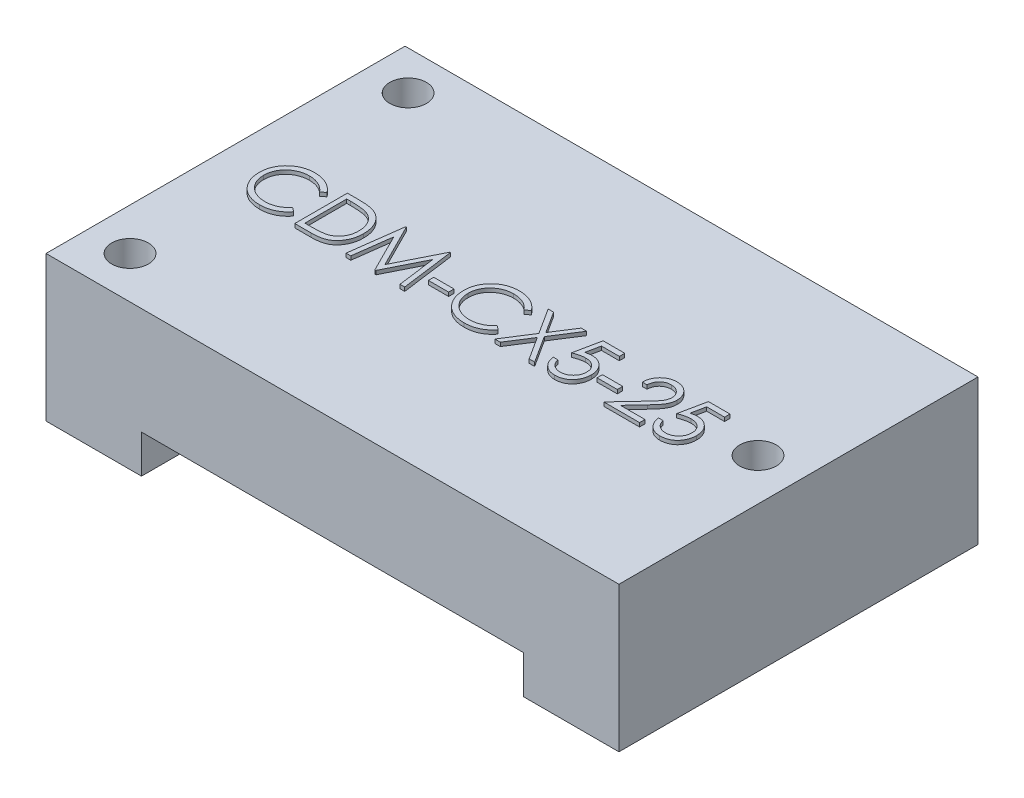
from build123d import *

# Parameters (mm, degrees)
SKETCH1_W               = 38.1
SKETCH1_H               = 23.876
SKETCH1_R               = 1.2192
BOSS_EXTRUDE1_DEPTH     = 9.652
SKETCH2_W               = 1.346153846
SKETCH2_H               = 0.358974359
BOSS_EXTRUDE2_DEPTH     = 0.254
SKETCH4_W               = 25.4
SKETCH4_H               = 2.54
CUT_EXTRUDE1_DEPTH      = 12.9380001
CUT_EXTRUDE1_DEPTH_BACK = 12.9380001


with BuildPart() as part:
    # Sketch1 → Boss-Extrude1 (new body)
    with BuildSketch(Plane(origin=(0, 0, 0), x_dir=(1, 0, 0), z_dir=(0, 1, 0))):
        Rectangle(SKETCH1_W, SKETCH1_H)
        with Locations((-16.256, 9.3472)):
            Circle(SKETCH1_R, mode=Mode.SUBTRACT)
        with Locations((-16.256, -9.144)):
            Circle(SKETCH1_R, mode=Mode.SUBTRACT)
        with Locations((16.256, 0.1016)):
            Circle(SKETCH1_R, mode=Mode.SUBTRACT)
    extrude(amount=-BOSS_EXTRUDE1_DEPTH)

    # Sketch2 → Boss-Extrude2 (add)
    with BuildSketch(Plane(origin=(0, 0, 0), x_dir=(1, 0, 0), z_dir=(0, 1, 0))):
        with BuildLine():
            Line((-12.967255042, 0.660782807), (-13.242094786, 0.450446269))
            add(Edge.make_bspline(
                [(-13.242094786, 0.450446269), (-13.261700674, 0.473812239), (-13.300648121, 0.520229154), (-13.363307324, 0.585408699), (-13.428608966, 0.64647396), (-13.496528088, 0.70371584), (-13.568287207, 0.755132606), (-13.642148006, 0.803403708), (-13.719346051, 0.846671446), (-13.826097786, 0.899134433), (-13.965745634, 0.953880588), (-14.141540473, 0.999783819), (-14.325051572, 1.029004995), (-14.450249171, 1.032169836), (-14.513929722, 1.033779602)],
                knots=[0, 0, 0, 0, 9.1485e-05, 0.000181737, 0.000271024, 0.000359627, 0.000447979, 0.000535687, 0.000624217, 0.000713268, 0.000892422, 0.00107303, 0.001257466, 0.001448389, 0.001448389, 0.001448389, 0.001448389], degree=3))
            add(Edge.make_bspline(
                [(-14.513929722, 1.033779602), (-14.549013021, 1.03337564), (-14.618854014, 1.032571464), (-14.722502487, 1.021962338), (-14.824215538, 1.007051128), (-14.923927005, 0.984925805), (-15.021509963, 0.956953186), (-15.117602365, 0.923527772), (-15.210812965, 0.882172932), (-15.302431203, 0.836464672), (-15.390210414, 0.784837228), (-15.473265462, 0.728523876), (-15.55129343, 0.668154779), (-15.624356042, 0.603503673), (-15.69252799, 0.534861712), (-15.755315301, 0.461497371), (-15.812500711, 0.383645197), (-15.865217736, 0.30233179), (-15.91243047, 0.217793998), (-15.951960349, 0.129718928), (-15.986965471, 0.039614825), (-16.014664714, -0.053536336), (-16.036589231, -0.149079102), (-16.051716894, -0.24726989), (-16.062205365, -0.347903569), (-16.063005542, -0.416112882), (-16.063408888, -0.450495238)],
                knots=[0, 0, 0, 0, 0.000105206, 0.000209435, 0.000312261, 0.00041348, 0.000515565, 0.000616682, 0.000718413, 0.000821258, 0.000923708, 0.001023662, 0.001122111, 0.001219464, 0.00131614, 0.001412112, 0.001508869, 0.001605718, 0.001702691, 0.001799013, 0.001895107, 0.001992482, 0.002090281, 0.00218895, 0.002290387, 0.00239349, 0.00239349, 0.00239349, 0.00239349], degree=3))
            add(Edge.make_bspline(
                [(-16.063408888, -0.450495238), (-16.062147069, -0.502226558), (-16.059669655, -0.603794142), (-16.037621321, -0.752564753), (-16.00411623, -0.895085427), (-15.953900653, -1.030465269), (-15.891981602, -1.160373627), (-15.813740991, -1.282612481), (-15.723124453, -1.399029045), (-15.618850034, -1.506871993), (-15.504444218, -1.605385718), (-15.381696306, -1.6921363), (-15.250912019, -1.764451182), (-15.113535388, -1.824627129), (-14.968509274, -1.870883856), (-14.816094472, -1.90344798), (-14.656622477, -1.92469016), (-14.547653077, -1.926723848), (-14.492194946, -1.927758859)],
                knots=[0, 0, 0, 0, 0.000155106, 0.000304531, 0.000450265, 0.000593548, 0.000736853, 0.000881182, 0.001028026, 0.001178769, 0.001330408, 0.001480379, 0.001628835, 0.001777978, 0.001929641, 0.002084627, 0.002245075, 0.00241136, 0.00241136, 0.00241136, 0.00241136], degree=3))
            add(Edge.make_bspline(
                [(-14.492194946, -1.927758859), (-14.431092257, -1.92607008), (-14.310827548, -1.922746157), (-14.134459522, -1.894586908), (-13.965623756, -1.84892899), (-13.80431117, -1.785031068), (-13.650976523, -1.70196578), (-13.505379863, -1.601267903), (-13.367398293, -1.48197957), (-13.28442701, -1.390896442), (-13.242094786, -1.344425526)],
                knots=[0, 0, 0, 0, 0.00018322, 0.00036062, 0.000534275, 0.000707044, 0.000879893, 0.001056289, 0.001237208, 0.001425665, 0.001425665, 0.001425665, 0.001425665], degree=3))
            Line((-13.242094786, -1.344425526), (-12.967255042, -1.552658699))
            add(Edge.make_bspline(
                [(-12.967255042, -1.552658699), (-12.989373152, -1.581197151), (-13.033503427, -1.638137357), (-13.104961444, -1.718409067), (-13.180238742, -1.793913103), (-13.259894452, -1.864040724), (-13.343012243, -1.930195189), (-13.431084556, -1.990497021), (-13.522953588, -2.045787905), (-13.618308067, -2.09641483), (-13.71704668, -2.141332077), (-13.819051115, -2.179785844), (-13.92388169, -2.212910734), (-14.031543199, -2.240162671), (-14.142258956, -2.261433754), (-14.25562943, -2.275653429), (-14.371899305, -2.285395344), (-14.450340726, -2.28628326), (-14.490091581, -2.286733218)],
                knots=[0, 0, 0, 0, 0.000108293, 0.000216068, 0.000322162, 0.000427957, 0.000534281, 0.00064066, 0.000747915, 0.000855806, 0.000964371, 0.001073102, 0.001182643, 0.001294024, 0.001406092, 0.001520624, 0.001636667, 0.001755891, 0.001755891, 0.001755891, 0.001755891], degree=3))
            add(Edge.make_bspline(
                [(-14.490091581, -2.286733218), (-14.527735248, -2.286471226), (-14.602170938, -2.285953168), (-14.712069689, -2.277561001), (-14.81905927, -2.266111264), (-14.922833896, -2.248871133), (-15.023959871, -2.228526793), (-15.121520456, -2.201255536), (-15.216475666, -2.170706369), (-15.308444007, -2.134801383), (-15.397503707, -2.0942852), (-15.483367518, -2.048493641), (-15.56599595, -1.997811777), (-15.646201371, -1.943356766), (-15.722798955, -1.883379464), (-15.79645248, -1.81871283), (-15.867574956, -1.749574819), (-15.911577641, -1.699719966), (-15.933701356, -1.674653892)],
                knots=[0, 0, 0, 0, 0.0001129, 0.000223246, 0.000330481, 0.000435603, 0.000538732, 0.000639764, 0.000739316, 0.000837878, 0.000935767, 0.001032686, 0.001129604, 0.00122645, 0.001323362, 0.001421241, 0.001520399, 0.001620667, 0.001620667, 0.001620667, 0.001620667], degree=3))
            add(Edge.make_bspline(
                [(-15.933701356, -1.674653892), (-15.969137, -1.631112703), (-16.039580477, -1.544555992), (-16.12970616, -1.404270011), (-16.206853715, -1.257801802), (-16.269229636, -1.104381873), (-16.317992369, -0.944354486), (-16.351773564, -0.777638972), (-16.373725169, -0.604391029), (-16.376235458, -0.486554241), (-16.377511453, -0.426657097)],
                knots=[0, 0, 0, 0, 0.000168306, 0.00033458, 0.000499224, 0.000664315, 0.00083066, 0.00100034, 0.001174094, 0.001353718, 0.001353718, 0.001353718, 0.001353718], degree=3))
            add(Edge.make_bspline(
                [(-16.377511453, -0.426657097), (-16.375956259, -0.363701643), (-16.372896513, -0.239840719), (-16.346900717, -0.058066765), (-16.305081921, 0.116084634), (-16.245685032, 0.282288378), (-16.170379681, 0.441418658), (-16.077353067, 0.592259863), (-15.967685925, 0.735776663), (-15.842238357, 0.869791414), (-15.704671022, 0.992330767), (-15.557352208, 1.100136971), (-15.400570261, 1.189854487), (-15.23605241, 1.264850649), (-15.062566728, 1.322495112), (-14.880483359, 1.362848299), (-14.690144444, 1.387965415), (-14.560282018, 1.391140623), (-14.494298311, 1.392753961)],
                knots=[0, 0, 0, 0, 0.000188789, 0.000371431, 0.000549644, 0.000725278, 0.00089996, 0.001076844, 0.001255917, 0.001440951, 0.001626689, 0.001807878, 0.001987546, 0.002167657, 0.002349462, 0.002534866, 0.002726448, 0.002924344, 0.002924344, 0.002924344, 0.002924344], degree=3))
            add(Edge.make_bspline(
                [(-14.494298311, 1.392753961), (-14.45408384, 1.392271823), (-14.374483342, 1.391317479), (-14.25673069, 1.382011337), (-14.142088363, 1.366497731), (-14.030477381, 1.345381661), (-13.921354765, 1.319174339), (-13.815554524, 1.285034041), (-13.712455837, 1.24599751), (-13.612708929, 1.201039044), (-13.516792379, 1.150572302), (-13.42473606, 1.095156679), (-13.337271201, 1.034860873), (-13.253782353, 0.970197698), (-13.175666142, 0.899799139), (-13.100704663, 0.825601543), (-13.031443585, 0.745467718), (-12.98869039, 0.689062784), (-12.967255042, 0.660782807)],
                knots=[0, 0, 0, 0, 0.000120626, 0.000238766, 0.000354085, 0.000467531, 0.000579423, 0.000690512, 0.000800803, 0.000910007, 0.001018518, 0.001125773, 0.001232152, 0.001337058, 0.001442329, 0.001547432, 0.001653292, 0.001759736, 0.001759736, 0.001759736, 0.001759736], degree=3))
        make_face()
        with BuildLine():
            Line((-12.249306324, -2.196989629), (-12.249306324, 1.303010371))
            Line((-12.249306324, 1.303010371), (-11.542575555, 1.303010371))
            add(Edge.make_bspline(
                [(-11.542575555, 1.303010371), (-11.481106567, 1.302567801), (-11.362348802, 1.301712758), (-11.190736354, 1.296291367), (-11.031952592, 1.286700901), (-10.886519733, 1.272731375), (-10.754038521, 1.255578342), (-10.634879912, 1.234077937), (-10.52842777, 1.208689767), (-10.462958329, 1.187044317), (-10.431998632, 1.176808448)],
                knots=[0, 0, 0, 0, 0.000184407, 0.000356273, 0.000515031, 0.000661537, 0.000794508, 0.000915664, 0.001024665, 0.001122454, 0.001122454, 0.001122454, 0.001122454], degree=3))
            add(Edge.make_bspline(
                [(-10.431998632, 1.176808448), (-10.391503893, 1.161377743), (-10.3114327, 1.130866249), (-10.197425578, 1.073309947), (-10.090100215, 1.008096845), (-9.98888107, 0.935140983), (-9.896080244, 0.852376634), (-9.808072347, 0.763319549), (-9.728457623, 0.664731208), (-9.655549327, 0.55865622), (-9.589813668, 0.446344168), (-9.53267451, 0.32800906), (-9.485220516, 0.204251851), (-9.44582729, 0.075416703), (-9.414780832, -0.058779674), (-9.393598901, -0.19849354), (-9.379627911, -0.34317273), (-9.378223859, -0.441347194), (-9.377511453, -0.491160302)],
                knots=[0, 0, 0, 0, 0.000129935, 0.000256923, 0.000382457, 0.000506429, 0.000630624, 0.000755071, 0.000881654, 0.001010204, 0.001140916, 0.00127168, 0.001403968, 0.001538146, 0.001675568, 0.001816774, 0.001961818, 0.002111216, 0.002111216, 0.002111216, 0.002111216], degree=3))
            add(Edge.make_bspline(
                [(-9.377511453, -0.491160302), (-9.37814042, -0.53442154), (-9.379379866, -0.619672329), (-9.390509182, -0.745313225), (-9.406685502, -0.867226796), (-9.4317297, -0.984832496), (-9.462132213, -1.099160714), (-9.501096365, -1.208992958), (-9.545731861, -1.315336768), (-9.597781739, -1.416754244), (-9.654923124, -1.512837616), (-9.716244868, -1.603413144), (-9.781681563, -1.687188366), (-9.851857196, -1.764416978), (-9.925864912, -1.834982556), (-10.004189243, -1.899474572), (-10.087032294, -1.956631127), (-10.174023016, -2.008698235), (-10.267699146, -2.05411859), (-10.369835012, -2.0925486), (-10.48086619, -2.124395215), (-10.600520147, -2.150966111), (-10.729003624, -2.172043414), (-10.86644259, -2.186169806), (-11.01262588, -2.195722739), (-11.113005145, -2.196559132), (-11.164670908, -2.196989629)],
                knots=[0, 0, 0, 0, 0.000129755, 0.000255696, 0.000378151, 0.000498469, 0.000616165, 0.000732801, 0.000847787, 0.000961923, 0.00107447, 0.001182981, 0.001289856, 0.001393094, 0.001495748, 0.001596383, 0.00169713, 0.001797413, 0.001900265, 0.002008995, 0.002124372, 0.002246504, 0.002376522, 0.002514729, 0.002660846, 0.00281582, 0.00281582, 0.00281582, 0.00281582], degree=3))
            Line((-11.164670908, -2.196989629), (-12.249306324, -2.196989629))
        make_face()
        with BuildLine():
            Line((-11.93520376, -1.83801527), (-11.533460972, -1.83801527))
            add(Edge.make_bspline(
                [(-11.533460972, -1.83801527), (-11.475732601, -1.837767173), (-11.364699803, -1.837289993), (-11.205041805, -1.83310279), (-11.059162409, -1.826260853), (-10.927040899, -1.816685775), (-10.808751875, -1.80401716), (-10.704048125, -1.789892257), (-10.613272867, -1.772294806), (-10.55834343, -1.756343847), (-10.53296017, -1.748972802)],
                knots=[0, 0, 0, 0, 0.000173183, 0.000333094, 0.000479096, 0.000611272, 0.000730431, 0.000835931, 0.000928194, 0.001007458, 0.001007458, 0.001007458, 0.001007458], degree=3))
            add(Edge.make_bspline(
                [(-10.53296017, -1.748972802), (-10.501011808, -1.737721244), (-10.43787817, -1.71548687), (-10.346997085, -1.674929209), (-10.26224008, -1.626887139), (-10.182130055, -1.573484865), (-10.1078034, -1.512838863), (-10.038379283, -1.446267875), (-9.973997482, -1.373433099), (-9.915323174, -1.294424938), (-9.86281487, -1.209735142), (-9.817343641, -1.120196309), (-9.777492109, -1.026789498), (-9.746213516, -0.92808034), (-9.721697932, -0.824951281), (-9.704333244, -0.717395068), (-9.69351852, -0.605431786), (-9.692257072, -0.529279662), (-9.691614017, -0.49045918)],
                knots=[0, 0, 0, 0, 0.000101593, 0.000200759, 0.000298073, 0.000393552, 0.000489254, 0.000585454, 0.000681817, 0.000780535, 0.000880346, 0.000980374, 0.001081551, 0.001184655, 0.001290601, 0.001399295, 0.001511268, 0.001627707, 0.001627707, 0.001627707, 0.001627707], degree=3))
            add(Edge.make_bspline(
                [(-9.691614017, -0.49045918), (-9.692127304, -0.4495257), (-9.693135662, -0.369111515), (-9.705809972, -0.25112082), (-9.724331527, -0.13764017), (-9.751115214, -0.028661974), (-9.785246092, 0.076026378), (-9.827840734, 0.175845888), (-9.876507353, 0.271850757), (-9.93441069, 0.361825123), (-9.997826284, 0.446918232), (-10.068204163, 0.524873148), (-10.144426201, 0.595867448), (-10.225661051, 0.661006761), (-10.31419815, 0.717670436), (-10.407951841, 0.768357117), (-10.508297512, 0.811373009), (-10.578110208, 0.834251872), (-10.613589177, 0.845878961)],
                knots=[0, 0, 0, 0, 0.000122746, 0.000241136, 0.000355593, 0.000467485, 0.000577457, 0.000685538, 0.00079278, 0.000899951, 0.001006101, 0.00111085, 0.001214524, 0.001318328, 0.001422759, 0.001529413, 0.00163777, 0.001749741, 0.001749741, 0.001749741, 0.001749741], degree=3))
            add(Edge.make_bspline(
                [(-10.613589177, 0.845878961), (-10.642940323, 0.853995389), (-10.705348914, 0.871253141), (-10.807188378, 0.890078514), (-10.921803527, 0.906683013), (-11.049703228, 0.920741052), (-11.190741687, 0.930828374), (-11.345027375, 0.938399688), (-11.51262698, 0.943506321), (-11.628809514, 0.943855028), (-11.68911001, 0.944036012)],
                knots=[0, 0, 0, 0, 9.1321e-05, 0.000194173, 0.000310382, 0.000438754, 0.000580072, 0.000734511, 0.000902151, 0.001083046, 0.001083046, 0.001083046, 0.001083046], degree=3))
            Line((-11.68911001, 0.944036012), (-11.93520376, 0.944036012))
            Line((-11.93520376, 0.944036012), (-11.93520376, -1.83801527))
        make_face(mode=Mode.SUBTRACT)
        Polygon((-8.839049914, -2.196989629), (-8.377010651, 1.303010371), (-8.332138856, 1.303010371), (-6.887126837, -1.5687845), (-5.445620427, 1.303010371), (-5.40004751, 1.303010371), (-4.93520376, -2.196989629), (-5.250708568, -2.196989629), (-5.585844786, 0.321439858), (-6.84926626, -2.196989629), (-6.920079561, -2.196989629), (-8.188408888, 0.327048833), (-8.522843985, -2.196989629), align=None)
        with Locations((-3.858280683, -0.850835783)):
            Rectangle(SKETCH2_W, SKETCH2_H)
        with BuildLine():
            Line((0.628898804, 0.660782807), (0.35405906, 0.450446269))
            add(Edge.make_bspline(
                [(0.35405906, 0.450446269), (0.334453172, 0.473812239), (0.295505725, 0.520229154), (0.232846523, 0.585408699), (0.16754488, 0.64647396), (0.099625758, 0.70371584), (0.027866639, 0.755132606), (-0.04599416, 0.803403708), (-0.123192205, 0.846671446), (-0.22994394, 0.899134433), (-0.369591788, 0.953880588), (-0.545386627, 0.999783819), (-0.728897725, 1.029004995), (-0.854095325, 1.032169836), (-0.917775876, 1.033779602)],
                knots=[0, 0, 0, 0, 9.1485e-05, 0.000181737, 0.000271024, 0.000359627, 0.000447979, 0.000535687, 0.000624217, 0.000713268, 0.000892422, 0.00107303, 0.001257466, 0.001448389, 0.001448389, 0.001448389, 0.001448389], degree=3))
            add(Edge.make_bspline(
                [(-0.917775876, 1.033779602), (-0.952859175, 1.03337564), (-1.022700168, 1.032571464), (-1.126348641, 1.021962338), (-1.228061692, 1.007051128), (-1.327773158, 0.984925805), (-1.425356117, 0.956953186), (-1.521448519, 0.923527772), (-1.614659119, 0.882172932), (-1.706277357, 0.836464672), (-1.794056568, 0.784837228), (-1.877111616, 0.728523876), (-1.955139584, 0.668154779), (-2.028202196, 0.603503673), (-2.096374144, 0.534861712), (-2.159161455, 0.461497371), (-2.216346865, 0.383645197), (-2.26906389, 0.30233179), (-2.316276624, 0.217793998), (-2.355806503, 0.129718928), (-2.390811625, 0.039614825), (-2.418510868, -0.053536336), (-2.440435385, -0.149079102), (-2.455563048, -0.24726989), (-2.466051519, -0.347903569), (-2.466851696, -0.416112882), (-2.467255042, -0.450495238)],
                knots=[0, 0, 0, 0, 0.000105206, 0.000209435, 0.000312261, 0.00041348, 0.000515565, 0.000616682, 0.000718413, 0.000821258, 0.000923708, 0.001023662, 0.001122111, 0.001219464, 0.00131614, 0.001412112, 0.001508869, 0.001605718, 0.001702691, 0.001799013, 0.001895107, 0.001992482, 0.002090281, 0.00218895, 0.002290387, 0.00239349, 0.00239349, 0.00239349, 0.00239349], degree=3))
            add(Edge.make_bspline(
                [(-2.467255042, -0.450495238), (-2.465993223, -0.502226558), (-2.463515809, -0.603794142), (-2.441467475, -0.752564753), (-2.407962384, -0.895085427), (-2.357746807, -1.030465269), (-2.295827756, -1.160373627), (-2.217587145, -1.282612481), (-2.126970607, -1.399029045), (-2.022696188, -1.506871993), (-1.908290372, -1.605385718), (-1.78554246, -1.6921363), (-1.654758172, -1.764451182), (-1.517381542, -1.824627129), (-1.372355428, -1.870883856), (-1.219940626, -1.90344798), (-1.060468631, -1.92469016), (-0.951499231, -1.926723848), (-0.8960411, -1.927758859)],
                knots=[0, 0, 0, 0, 0.000155106, 0.000304531, 0.000450265, 0.000593548, 0.000736853, 0.000881182, 0.001028026, 0.001178769, 0.001330408, 0.001480379, 0.001628835, 0.001777978, 0.001929641, 0.002084627, 0.002245075, 0.00241136, 0.00241136, 0.00241136, 0.00241136], degree=3))
            add(Edge.make_bspline(
                [(-0.8960411, -1.927758859), (-0.834938411, -1.92607008), (-0.714673702, -1.922746157), (-0.538305676, -1.894586908), (-0.36946991, -1.84892899), (-0.208157324, -1.785031068), (-0.054822677, -1.70196578), (0.090773983, -1.601267903), (0.228755553, -1.48197957), (0.311726836, -1.390896442), (0.35405906, -1.344425526)],
                knots=[0, 0, 0, 0, 0.00018322, 0.00036062, 0.000534275, 0.000707044, 0.000879893, 0.001056289, 0.001237208, 0.001425665, 0.001425665, 0.001425665, 0.001425665], degree=3))
            Line((0.35405906, -1.344425526), (0.628898804, -1.552658699))
            add(Edge.make_bspline(
                [(0.628898804, -1.552658699), (0.606780694, -1.581197151), (0.562650419, -1.638137357), (0.491192402, -1.718409067), (0.415915104, -1.793913103), (0.336259394, -1.864040724), (0.253141603, -1.930195189), (0.16506929, -1.990497021), (0.073200258, -2.045787905), (-0.022154221, -2.09641483), (-0.120892834, -2.141332077), (-0.222897269, -2.179785844), (-0.327727844, -2.212910734), (-0.435389353, -2.240162671), (-0.546105109, -2.261433754), (-0.659475584, -2.275653429), (-0.775745459, -2.285395344), (-0.85418688, -2.28628326), (-0.893937735, -2.286733218)],
                knots=[0, 0, 0, 0, 0.000108293, 0.000216068, 0.000322162, 0.000427957, 0.000534281, 0.00064066, 0.000747915, 0.000855806, 0.000964371, 0.001073102, 0.001182643, 0.001294024, 0.001406092, 0.001520624, 0.001636667, 0.001755891, 0.001755891, 0.001755891, 0.001755891], degree=3))
            add(Edge.make_bspline(
                [(-0.893937735, -2.286733218), (-0.931581402, -2.286471226), (-1.006017092, -2.285953168), (-1.115915843, -2.277561001), (-1.222905424, -2.266111264), (-1.32668005, -2.248871133), (-1.427806025, -2.228526793), (-1.52536661, -2.201255536), (-1.62032182, -2.170706369), (-1.712290161, -2.134801383), (-1.80134986, -2.0942852), (-1.887213672, -2.048493641), (-1.969842104, -1.997811777), (-2.050047525, -1.943356766), (-2.126645109, -1.883379464), (-2.200298634, -1.81871283), (-2.27142111, -1.749574819), (-2.315423795, -1.699719966), (-2.33754751, -1.674653892)],
                knots=[0, 0, 0, 0, 0.0001129, 0.000223246, 0.000330481, 0.000435603, 0.000538732, 0.000639764, 0.000739316, 0.000837878, 0.000935767, 0.001032686, 0.001129604, 0.00122645, 0.001323362, 0.001421241, 0.001520399, 0.001620667, 0.001620667, 0.001620667, 0.001620667], degree=3))
            add(Edge.make_bspline(
                [(-2.33754751, -1.674653892), (-2.372983154, -1.631112703), (-2.443426631, -1.544555992), (-2.533552314, -1.404270011), (-2.610699869, -1.257801802), (-2.67307579, -1.104381873), (-2.721838523, -0.944354486), (-2.755619718, -0.777638972), (-2.777571323, -0.604391029), (-2.780081612, -0.486554241), (-2.781357606, -0.426657097)],
                knots=[0, 0, 0, 0, 0.000168306, 0.00033458, 0.000499224, 0.000664315, 0.00083066, 0.00100034, 0.001174094, 0.001353718, 0.001353718, 0.001353718, 0.001353718], degree=3))
            add(Edge.make_bspline(
                [(-2.781357606, -0.426657097), (-2.779802413, -0.363701643), (-2.776742667, -0.239840719), (-2.750746871, -0.058066765), (-2.708928075, 0.116084634), (-2.649531186, 0.282288378), (-2.574225835, 0.441418658), (-2.481199221, 0.592259863), (-2.371532079, 0.735776663), (-2.246084511, 0.869791414), (-2.108517176, 0.992330767), (-1.961198362, 1.100136971), (-1.804416415, 1.189854487), (-1.639898563, 1.264850649), (-1.466412882, 1.322495112), (-1.284329513, 1.362848299), (-1.093990598, 1.387965415), (-0.964128172, 1.391140623), (-0.898144465, 1.392753961)],
                knots=[0, 0, 0, 0, 0.000188789, 0.000371431, 0.000549644, 0.000725278, 0.00089996, 0.001076844, 0.001255917, 0.001440951, 0.001626689, 0.001807878, 0.001987546, 0.002167657, 0.002349462, 0.002534866, 0.002726448, 0.002924344, 0.002924344, 0.002924344, 0.002924344], degree=3))
            add(Edge.make_bspline(
                [(-0.898144465, 1.392753961), (-0.857929993, 1.392271823), (-0.778329496, 1.391317479), (-0.660576844, 1.382011337), (-0.545934517, 1.366497731), (-0.434323535, 1.345381661), (-0.325200918, 1.319174339), (-0.219400678, 1.285034041), (-0.116301991, 1.24599751), (-0.016555083, 1.201039044), (0.079361468, 1.150572302), (0.171417786, 1.095156679), (0.258882645, 1.034860873), (0.342371493, 0.970197698), (0.420487704, 0.899799139), (0.495449183, 0.825601543), (0.564710261, 0.745467718), (0.607463456, 0.689062784), (0.628898804, 0.660782807)],
                knots=[0, 0, 0, 0, 0.000120626, 0.000238766, 0.000354085, 0.000467531, 0.000579423, 0.000690512, 0.000800803, 0.000910007, 0.001018518, 0.001125773, 0.001232152, 0.001337058, 0.001442329, 0.001547432, 0.001653292, 0.001759736, 0.001759736, 0.001759736, 0.001759736], degree=3))
        make_face()
        Polygon((1.10005265, 1.303010371), (1.462532618, 1.303010371), (2.378898804, -0.128680334), (3.29526499, 1.303010371), (3.657744958, 1.303010371), (2.560489349, -0.411933539), (3.702616753, -2.196989629), (3.340136785, -2.196989629), (2.378898804, -0.695186744), (1.417660823, -2.196989629), (1.055180855, -2.196989629), (2.198009381, -0.411933539), align=None)
        with BuildLine():
            Line((6.193001368, 1.303010371), (6.193001368, 0.944036012))
            Line((6.193001368, 0.944036012), (5.00249656, 0.944036012))
            Line((5.00249656, 0.944036012), (4.813894797, 0.023463096))
            add(Edge.make_bspline(
                [(4.813894797, 0.023463096), (4.850950672, 0.033693367), (4.922740568, 0.053512901), (5.028700429, 0.075518672), (5.129292632, 0.088784116), (5.194568003, 0.090595426), (5.226154413, 0.09147191)],
                knots=[0, 0, 0, 0, 0.000115302, 0.000223379, 0.000324431, 0.000419176, 0.000419176, 0.000419176, 0.000419176], degree=3))
            add(Edge.make_bspline(
                [(5.226154413, 0.09147191), (5.265238153, 0.090625974), (5.34208655, 0.088962653), (5.454525497, 0.072990804), (5.56185839, 0.047850889), (5.66386076, 0.012730367), (5.760721311, -0.032179366), (5.851548872, -0.088279306), (5.937706785, -0.153812637), (6.017649379, -0.229157649), (6.090173688, -0.312079266), (6.153939677, -0.401237137), (6.208102267, -0.495764799), (6.251663022, -0.596565408), (6.286447357, -0.702524561), (6.309599351, -0.814757144), (6.32501606, -0.932205264), (6.326738447, -1.012509834), (6.327616753, -1.053459981)],
                knots=[0, 0, 0, 0, 0.00011719, 0.000230425, 0.000339944, 0.000447481, 0.000553499, 0.000659556, 0.000767111, 0.000877722, 0.000988528, 0.001097091, 0.001206056, 0.001314692, 0.001425996, 0.001539995, 0.001658004, 0.001780798, 0.001780798, 0.001780798, 0.001780798], degree=3))
            add(Edge.make_bspline(
                [(6.327616753, -1.053459981), (6.326951677, -1.081982202), (6.325630515, -1.138641189), (6.318911927, -1.22278539), (6.305976211, -1.305148223), (6.288608487, -1.385740615), (6.266066069, -1.464409987), (6.238777015, -1.541381515), (6.205380988, -1.616176122), (6.168749612, -1.689501517), (6.127503134, -1.759700024), (6.081724627, -1.82534901), (6.033359136, -1.887433292), (5.98131775, -1.945287025), (5.925116755, -1.998530043), (5.865436788, -2.047478324), (5.802754069, -2.092959655), (5.736098827, -2.13312785), (5.666956344, -2.170090806), (5.594328127, -2.200414343), (5.519867426, -2.227524871), (5.442502551, -2.249134399), (5.362408738, -2.266066953), (5.279453963, -2.277567554), (5.194073293, -2.285943992), (5.13619828, -2.286468348), (5.106963708, -2.286733218)],
                knots=[0, 0, 0, 0, 8.5583e-05, 0.000170009, 0.000253005, 0.000335518, 0.000417186, 0.000498352, 0.000580291, 0.000662755, 0.000744161, 0.000824288, 0.000902692, 0.000980133, 0.001057498, 0.001134702, 0.00121156, 0.001289599, 0.001368002, 0.001446531, 0.001525481, 0.001605609, 0.001687289, 0.001770875, 0.001856759, 0.001944425, 0.001944425, 0.001944425, 0.001944425], degree=3))
            add(Edge.make_bspline(
                [(5.106963708, -2.286733218), (5.072089527, -2.28604238), (5.003478696, -2.284683238), (4.902958129, -2.270464753), (4.806243524, -2.250100837), (4.714113422, -2.219464567), (4.625742159, -2.181077272), (4.542319441, -2.132561101), (4.461713665, -2.077581997), (4.387201628, -2.012701644), (4.318045515, -1.941785962), (4.256139006, -1.864828321), (4.201005429, -1.783098879), (4.153527682, -1.696200725), (4.113029661, -1.604362194), (4.081214672, -1.507239193), (4.055536318, -1.405339189), (4.044672897, -1.335185678), (4.039155214, -1.299553731)],
                knots=[0, 0, 0, 0, 0.000104552, 0.000205693, 0.000304023, 0.000400691, 0.00049644, 0.000592535, 0.000689779, 0.000788716, 0.000888377, 0.000986596, 0.001084603, 0.001183757, 0.001283279, 0.001385267, 0.001490017, 0.001598135, 0.001598135, 0.001598135, 0.001598135], degree=3))
            Line((4.039155214, -1.299553731), (4.353257778, -1.299553731))
            add(Edge.make_bspline(
                [(4.353257778, -1.299553731), (4.360986336, -1.332930184), (4.375841052, -1.397081579), (4.408446801, -1.48721292), (4.448312676, -1.567532144), (4.495717025, -1.639101727), (4.552267055, -1.701510724), (4.616796484, -1.757127786), (4.689144207, -1.807302915), (4.769537437, -1.849125683), (4.854350516, -1.884794436), (4.943117726, -1.908546131), (5.033422073, -1.925247024), (5.094500443, -1.926918785), (5.125192874, -1.927758859)],
                knots=[0, 0, 0, 0, 0.000102709, 0.000197412, 0.000286774, 0.000371169, 0.000454082, 0.000538572, 0.000626283, 0.000717552, 0.000809994, 0.00090168, 0.00099274, 0.001084718, 0.001084718, 0.001084718, 0.001084718], degree=3))
            add(Edge.make_bspline(
                [(5.125192874, -1.927758859), (5.155151319, -1.926938082), (5.214139741, -1.925321963), (5.300951128, -1.912882951), (5.384764002, -1.89372538), (5.464751359, -1.865055525), (5.542312898, -1.830210806), (5.615486669, -1.785495731), (5.686389546, -1.734035712), (5.752817679, -1.675079082), (5.813657129, -1.610109387), (5.86741325, -1.540631994), (5.912190163, -1.466515147), (5.949924272, -1.389041995), (5.978577571, -1.307363437), (5.999018552, -1.221862262), (6.011021611, -1.132327282), (6.012672791, -1.071257972), (6.013514189, -1.040138667)],
                knots=[0, 0, 0, 0, 8.9842e-05, 0.0001769, 0.000262612, 0.000347317, 0.000431396, 0.000517249, 0.000604055, 0.000693954, 0.000783242, 0.000870748, 0.000956963, 0.001042571, 0.001128832, 0.00121607, 0.001305907, 0.001399251, 0.001399251, 0.001399251, 0.001399251], degree=3))
            add(Edge.make_bspline(
                [(6.013514189, -1.040138667), (6.012855709, -1.012062916), (6.011566829, -0.957108626), (6.001036259, -0.87670942), (5.982719287, -0.800636378), (5.957295407, -0.728522144), (5.925015899, -0.660298701), (5.885569587, -0.595895641), (5.838216189, -0.536161808), (5.7841243, -0.481069254), (5.724866259, -0.43022438), (5.659422516, -0.386880293), (5.58916259, -0.350416375), (5.51493299, -0.318948377), (5.434968092, -0.296347632), (5.350851459, -0.279379746), (5.261674751, -0.269564384), (5.200704063, -0.268202495), (5.169363547, -0.267502449)],
                knots=[0, 0, 0, 0, 8.4208e-05, 0.000164824, 0.000242709, 0.000318547, 0.000393815, 0.000468731, 0.000544614, 0.00062196, 0.000700062, 0.000778428, 0.000856831, 0.000937299, 0.001019835, 0.001105635, 0.00119452, 0.001288536, 0.001288536, 0.001288536, 0.001288536], degree=3))
            add(Edge.make_bspline(
                [(5.169363547, -0.267502449), (5.142234619, -0.26808304), (5.086220263, -0.269281814), (5.000297437, -0.278108311), (4.910005714, -0.292347605), (4.815691218, -0.311933853), (4.71707071, -0.337564929), (4.614352309, -0.36827943), (4.507320043, -0.405001429), (4.435202318, -0.432733642), (4.398129573, -0.446989629)],
                knots=[0, 0, 0, 0, 8.1378e-05, 0.000168026, 0.000258858, 0.000355524, 0.000456875, 0.000564457, 0.000677092, 0.000796243, 0.000796243, 0.000796243, 0.000796243], degree=3))
            Line((4.398129573, -0.446989629), (4.757103932, 1.303010371))
            Line((4.757103932, 1.303010371), (6.193001368, 1.303010371))
        make_face()
        with Locations((7.359668035, -0.850835783)):
            Rectangle(SKETCH2_W, SKETCH2_H)
        with BuildLine():
            Line((8.750693676, 0.226087294), (8.436591112, 0.226087294))
            add(Edge.make_bspline(
                [(8.436591112, 0.226087294), (8.438638265, 0.267758182), (8.442658819, 0.349598697), (8.461487108, 0.468922603), (8.488427985, 0.582977402), (8.526519439, 0.690847316), (8.573825717, 0.793486123), (8.630555744, 0.890486139), (8.697749595, 0.981477327), (8.773956329, 1.065616171), (8.856724968, 1.142803742), (8.946030907, 1.209458984), (9.039875935, 1.265776656), (9.137975334, 1.312857898), (9.241435897, 1.348197743), (9.349318755, 1.374419383), (9.462097891, 1.390195729), (9.538937913, 1.391891514), (9.578017394, 1.392753961)],
                knots=[0, 0, 0, 0, 0.000125083, 0.00024566, 0.000361805, 0.000476223, 0.000588214, 0.000700404, 0.000812728, 0.00092691, 0.001040529, 0.001151727, 0.001260545, 0.001368429, 0.001477521, 0.001587884, 0.001701119, 0.00181831, 0.00181831, 0.00181831, 0.00181831], degree=3))
            add(Edge.make_bspline(
                [(9.578017394, 1.392753961), (9.616395468, 1.391855505), (9.691807012, 1.39009007), (9.801869027, 1.374929041), (9.906646321, 1.351183449), (10.005934088, 1.317868033), (10.098940152, 1.273083605), (10.186363197, 1.219286067), (10.269244008, 1.157066235), (10.343850791, 1.083812422), (10.412358871, 1.005610037), (10.471461126, 0.922122134), (10.522074289, 0.835892848), (10.564261969, 0.746264646), (10.595318108, 0.652393618), (10.618896316, 0.555646415), (10.63222373, 0.455021604), (10.634269153, 0.386915048), (10.63530906, 0.352289217)],
                knots=[0, 0, 0, 0, 0.000115089, 0.000226145, 0.000332614, 0.000437044, 0.000539592, 0.000641561, 0.000744629, 0.00084975, 0.000954621, 0.001056175, 0.001156101, 0.001254284, 0.001352726, 0.001452208, 0.001552655, 0.001656537, 0.001656537, 0.001656537, 0.001656537], degree=3))
            add(Edge.make_bspline(
                [(10.63530906, 0.352289217), (10.633615797, 0.303541383), (10.630258986, 0.206901169), (10.60154461, 0.064886306), (10.556698098, -0.072707113), (10.502700742, -0.183444415), (10.448228298, -0.272677908), (10.39914079, -0.346146613), (10.341675979, -0.425252082), (10.274997481, -0.509729419), (10.200484609, -0.600240324), (10.117462445, -0.69673012), (10.025338963, -0.798201889), (9.960680463, -0.867507491), (9.927176047, -0.903419917)],
                knots=[0, 0, 0, 0, 0.000146118, 0.000289672, 0.0004329, 0.00057934, 0.000657978, 0.000746456, 0.000844345, 0.000951219, 0.001069268, 0.00119604, 0.001333047, 0.001480391, 0.001480391, 0.001480391, 0.001480391], degree=3))
            Line((9.927176047, -0.903419917), (9.051474926, -1.83801527))
            Line((9.051474926, -1.83801527), (10.680180855, -1.83801527))
            Line((10.680180855, -1.83801527), (10.680180855, -2.196989629))
            Line((10.680180855, -2.196989629), (8.301975727, -2.196989629))
            Line((8.301975727, -2.196989629), (9.659347522, -0.748472))
            add(Edge.make_bspline(
                [(9.659347522, -0.748472), (9.692395409, -0.713973694), (9.755873636, -0.647709507), (9.845656213, -0.550966547), (9.926295201, -0.461217006), (9.998312594, -0.378630458), (10.060146099, -0.30199889), (10.115018331, -0.233804187), (10.158983922, -0.171049736), (10.206699318, -0.098309122), (10.252913299, -0.009496805), (10.292625655, 0.099036884), (10.316840504, 0.210764137), (10.319745339, 0.286266174), (10.321206496, 0.324244346)],
                knots=[0, 0, 0, 0, 0.000143319, 0.000275286, 0.00039593, 0.000505287, 0.000603949, 0.000691331, 0.000767782, 0.00083371, 0.000952247, 0.001067137, 0.001179618, 0.001293462, 0.001293462, 0.001293462, 0.001293462], degree=3))
            add(Edge.make_bspline(
                [(10.321206496, 0.324244346), (10.320570754, 0.348125744), (10.319317828, 0.395191394), (10.30826013, 0.464197153), (10.291549624, 0.530761967), (10.267604366, 0.595090586), (10.235997626, 0.656536238), (10.197524246, 0.715173719), (10.153134183, 0.771862684), (10.101782914, 0.825015982), (10.045371394, 0.873697187), (9.985777144, 0.916821273), (9.92272704, 0.952860384), (9.856486918, 0.982403881), (9.787241448, 1.005579262), (9.714856703, 1.021637841), (9.639532687, 1.031720325), (9.588099191, 1.033084497), (9.561891592, 1.033779602)],
                knots=[0, 0, 0, 0, 7.16e-05, 0.00014111, 0.00020913, 0.00027724, 0.000346538, 0.000415963, 0.000487357, 0.000562233, 0.000637292, 0.000710646, 0.000782564, 0.000854749, 0.000927915, 0.001001225, 0.001076884, 0.001155488, 0.001155488, 0.001155488, 0.001155488], degree=3))
            add(Edge.make_bspline(
                [(9.561891592, 1.033779602), (9.53452076, 1.03306457), (9.480768963, 1.031660365), (9.40184993, 1.021837701), (9.326564153, 1.00489186), (9.25472225, 0.981715186), (9.186202664, 0.952256637), (9.12133862, 0.915564892), (9.060275731, 0.871781399), (9.002899208, 0.822140843), (8.950035228, 0.766873242), (8.903588353, 0.705263278), (8.863004338, 0.638435863), (8.827595105, 0.566571313), (8.798839415, 0.489017533), (8.776866264, 0.406049828), (8.759479418, 0.318028446), (8.753670897, 0.257243361), (8.750693676, 0.226087294)],
                knots=[0, 0, 0, 0, 8.2106e-05, 0.000161243, 0.000238127, 0.000313291, 0.000387401, 0.000461495, 0.000536397, 0.000612445, 0.000688819, 0.000765383, 0.000843422, 0.000923066, 0.001005373, 0.001091093, 0.001180334, 0.001274175, 0.001274175, 0.001274175, 0.001274175], degree=3))
        make_face()
        with BuildLine():
            Line((13.193001368, 1.303010371), (13.193001368, 0.944036012))
            Line((13.193001368, 0.944036012), (12.00249656, 0.944036012))
            Line((12.00249656, 0.944036012), (11.813894797, 0.023463096))
            add(Edge.make_bspline(
                [(11.813894797, 0.023463096), (11.850950672, 0.033693367), (11.922740568, 0.053512901), (12.028700429, 0.075518672), (12.129292632, 0.088784116), (12.194568003, 0.090595426), (12.226154413, 0.09147191)],
                knots=[0, 0, 0, 0, 0.000115302, 0.000223379, 0.000324431, 0.000419176, 0.000419176, 0.000419176, 0.000419176], degree=3))
            add(Edge.make_bspline(
                [(12.226154413, 0.09147191), (12.265238153, 0.090625974), (12.34208655, 0.088962653), (12.454525497, 0.072990804), (12.56185839, 0.047850889), (12.66386076, 0.012730367), (12.760721311, -0.032179366), (12.851548872, -0.088279306), (12.937706785, -0.153812637), (13.017649379, -0.229157649), (13.090173688, -0.312079266), (13.153939677, -0.401237137), (13.208102267, -0.495764799), (13.251663022, -0.596565408), (13.286447357, -0.702524561), (13.309599351, -0.814757144), (13.32501606, -0.932205264), (13.326738447, -1.012509834), (13.327616753, -1.053459981)],
                knots=[0, 0, 0, 0, 0.00011719, 0.000230425, 0.000339944, 0.000447481, 0.000553499, 0.000659556, 0.000767111, 0.000877722, 0.000988528, 0.001097091, 0.001206056, 0.001314692, 0.001425996, 0.001539995, 0.001658004, 0.001780798, 0.001780798, 0.001780798, 0.001780798], degree=3))
            add(Edge.make_bspline(
                [(13.327616753, -1.053459981), (13.326951677, -1.081982202), (13.325630515, -1.138641189), (13.318911927, -1.22278539), (13.305976211, -1.305148223), (13.288608487, -1.385740615), (13.266066069, -1.464409987), (13.238777015, -1.541381515), (13.205380988, -1.616176122), (13.168749612, -1.689501517), (13.127503134, -1.759700024), (13.081724627, -1.82534901), (13.033359136, -1.887433292), (12.98131775, -1.945287025), (12.925116755, -1.998530043), (12.865436788, -2.047478324), (12.802754069, -2.092959655), (12.736098827, -2.13312785), (12.666956344, -2.170090806), (12.594328127, -2.200414343), (12.519867426, -2.227524871), (12.442502551, -2.249134399), (12.362408738, -2.266066953), (12.279453963, -2.277567554), (12.194073293, -2.285943992), (12.13619828, -2.286468348), (12.106963708, -2.286733218)],
                knots=[0, 0, 0, 0, 8.5583e-05, 0.000170009, 0.000253005, 0.000335518, 0.000417186, 0.000498352, 0.000580291, 0.000662755, 0.000744161, 0.000824288, 0.000902692, 0.000980133, 0.001057498, 0.001134702, 0.00121156, 0.001289599, 0.001368002, 0.001446531, 0.001525481, 0.001605609, 0.001687289, 0.001770875, 0.001856759, 0.001944425, 0.001944425, 0.001944425, 0.001944425], degree=3))
            add(Edge.make_bspline(
                [(12.106963708, -2.286733218), (12.072089527, -2.28604238), (12.003478696, -2.284683238), (11.902958129, -2.270464753), (11.806243524, -2.250100837), (11.714113422, -2.219464567), (11.625742159, -2.181077272), (11.542319441, -2.132561101), (11.461713665, -2.077581997), (11.387201628, -2.012701644), (11.318045515, -1.941785962), (11.256139006, -1.864828321), (11.201005429, -1.783098879), (11.153527682, -1.696200725), (11.113029661, -1.604362194), (11.081214672, -1.507239193), (11.055536318, -1.405339189), (11.044672897, -1.335185678), (11.039155214, -1.299553731)],
                knots=[0, 0, 0, 0, 0.000104552, 0.000205693, 0.000304023, 0.000400691, 0.00049644, 0.000592535, 0.000689779, 0.000788716, 0.000888377, 0.000986596, 0.001084603, 0.001183757, 0.001283279, 0.001385267, 0.001490017, 0.001598135, 0.001598135, 0.001598135, 0.001598135], degree=3))
            Line((11.039155214, -1.299553731), (11.353257778, -1.299553731))
            add(Edge.make_bspline(
                [(11.353257778, -1.299553731), (11.360986336, -1.332930184), (11.375841052, -1.397081579), (11.408446801, -1.48721292), (11.448312676, -1.567532144), (11.495717025, -1.639101727), (11.552267055, -1.701510724), (11.616796484, -1.757127786), (11.689144207, -1.807302915), (11.769537437, -1.849125683), (11.854350516, -1.884794436), (11.943117726, -1.908546131), (12.033422073, -1.925247024), (12.094500443, -1.926918785), (12.125192874, -1.927758859)],
                knots=[0, 0, 0, 0, 0.000102709, 0.000197412, 0.000286774, 0.000371169, 0.000454082, 0.000538572, 0.000626283, 0.000717552, 0.000809994, 0.00090168, 0.00099274, 0.001084718, 0.001084718, 0.001084718, 0.001084718], degree=3))
            add(Edge.make_bspline(
                [(12.125192874, -1.927758859), (12.155151319, -1.926938082), (12.214139741, -1.925321963), (12.300951128, -1.912882951), (12.384764002, -1.89372538), (12.464751359, -1.865055525), (12.542312898, -1.830210806), (12.615486669, -1.785495731), (12.686389546, -1.734035712), (12.752817679, -1.675079082), (12.813657129, -1.610109387), (12.86741325, -1.540631994), (12.912190163, -1.466515147), (12.949924272, -1.389041995), (12.978577571, -1.307363437), (12.999018552, -1.221862262), (13.011021611, -1.132327282), (13.012672791, -1.071257972), (13.013514189, -1.040138667)],
                knots=[0, 0, 0, 0, 8.9842e-05, 0.0001769, 0.000262612, 0.000347317, 0.000431396, 0.000517249, 0.000604055, 0.000693954, 0.000783242, 0.000870748, 0.000956963, 0.001042571, 0.001128832, 0.00121607, 0.001305907, 0.001399251, 0.001399251, 0.001399251, 0.001399251], degree=3))
            add(Edge.make_bspline(
                [(13.013514189, -1.040138667), (13.012855709, -1.012062916), (13.011566829, -0.957108626), (13.001036259, -0.87670942), (12.982719287, -0.800636378), (12.957295407, -0.728522144), (12.925015899, -0.660298701), (12.885569587, -0.595895641), (12.838216189, -0.536161808), (12.7841243, -0.481069254), (12.724866259, -0.43022438), (12.659422516, -0.386880293), (12.58916259, -0.350416375), (12.51493299, -0.318948377), (12.434968092, -0.296347632), (12.350851459, -0.279379746), (12.261674751, -0.269564384), (12.200704063, -0.268202495), (12.169363547, -0.267502449)],
                knots=[0, 0, 0, 0, 8.4208e-05, 0.000164824, 0.000242709, 0.000318547, 0.000393815, 0.000468731, 0.000544614, 0.00062196, 0.000700062, 0.000778428, 0.000856831, 0.000937299, 0.001019835, 0.001105635, 0.00119452, 0.001288536, 0.001288536, 0.001288536, 0.001288536], degree=3))
            add(Edge.make_bspline(
                [(12.169363547, -0.267502449), (12.142234619, -0.26808304), (12.086220263, -0.269281814), (12.000297437, -0.278108311), (11.910005714, -0.292347605), (11.815691218, -0.311933853), (11.71707071, -0.337564929), (11.614352309, -0.36827943), (11.507320043, -0.405001429), (11.435202318, -0.432733642), (11.398129573, -0.446989629)],
                knots=[0, 0, 0, 0, 8.1378e-05, 0.000168026, 0.000258858, 0.000355524, 0.000456875, 0.000564457, 0.000677092, 0.000796243, 0.000796243, 0.000796243, 0.000796243], degree=3))
            Line((11.398129573, -0.446989629), (11.757103932, 1.303010371))
            Line((11.757103932, 1.303010371), (13.193001368, 1.303010371))
        make_face()
    extrude(amount=BOSS_EXTRUDE2_DEPTH)

    # Sketch4 → Cut-Extrude1 (cut, two sides)
    with BuildSketch(Plane.XY) as cut_extrude1_sk:
        with Locations((0, -8.382)):
            Rectangle(SKETCH4_W, SKETCH4_H)
    extrude(amount=CUT_EXTRUDE1_DEPTH, mode=Mode.SUBTRACT)
    extrude(cut_extrude1_sk.sketch, amount=-CUT_EXTRUDE1_DEPTH_BACK, mode=Mode.SUBTRACT)


solid = part.part
